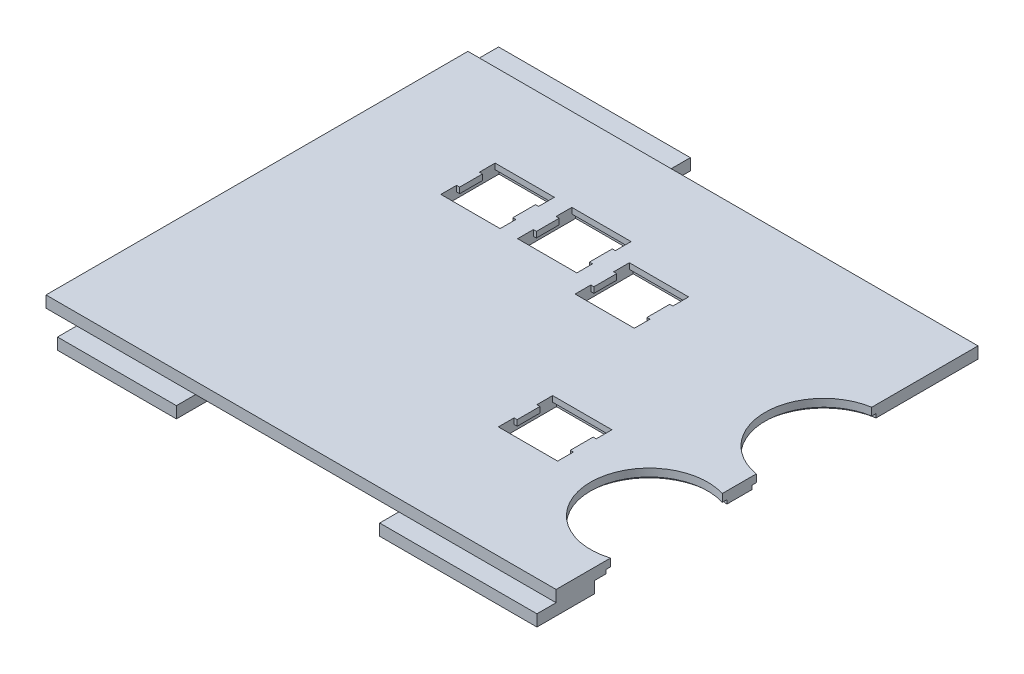
from build123d import *

# Parameters (mm, degrees)
SKETCH1_W           = 133
SKETCH1_H           = 110
BOSS_EXTRUDE1_DEPTH = 3
SKETCH2_W           = 50
SKETCH2_H           = 18
SKETCH2_W_2         = 41
SKETCH2_H_2         = 15
SKETCH2_W_3         = 31
BOSS_EXTRUDE2_DEPTH = 3
CUT_EXTRUDE1_REACH  = 8
SKETCH3_R           = 15.25
SKETCH4_R           = 16.375
CUT_EXTRUDE2_DEPTH  = 1
CUT_EXTRUDE3_DEPTH  = 7
SKETCH7_W           = 15.45
SKETCH7_H           = 16.15
CUT_EXTRUDE4_DEPTH  = 1.5


with BuildPart() as part:
    # Sketch1 → Boss-Extrude1 (new body)
    with BuildSketch(Plane(origin=(0, 0, 0), x_dir=(1, 0, 0), z_dir=(0, 1, 0))):
        with Locations((66.5, 55)):
            Rectangle(SKETCH1_W, SKETCH1_H)
    extrude(amount=BOSS_EXTRUDE1_DEPTH)

    # Sketch2 → Boss-Extrude2 (add)
    with BuildSketch(Plane.XZ):
        with Locations((25, -109)):
            Rectangle(SKETCH2_W, SKETCH2_H)
        with Locations((112.5, -2.5)):
            Rectangle(SKETCH2_W_2, SKETCH2_H_2)
        with Locations((23.5, -2.5)):
            Rectangle(SKETCH2_W_3, SKETCH2_H_2)
    extrude(amount=BOSS_EXTRUDE2_DEPTH)

    # Sketch3 → Cut-Extrude1 (cut, up to next)
    with BuildSketch(Plane(origin=(0, 3, 0), x_dir=(1, 0, 0), z_dir=(0, 1, 0)), mode=Mode.PRIVATE) as cut_extrude1_sk1:
        with Locations((128.5, 28.75)):
            Circle(SKETCH3_R)
    cut_extrude1_tool1 = extrude(cut_extrude1_sk1.sketch, amount=-CUT_EXTRUDE1_REACH, mode=Mode.PRIVATE) & part.part
    add(cut_extrude1_tool1.solids().sort_by_distance((128.5, 3, -28.75))[0], mode=Mode.SUBTRACT)
    # Sketch3 → Cut-Extrude1 (cut, up to next)
    with BuildSketch(Plane(origin=(0, 3, 0), x_dir=(1, 0, 0), z_dir=(0, 1, 0)), mode=Mode.PRIVATE) as cut_extrude1_sk2:
        with Locations((135.5, 67.25)):
            Circle(SKETCH3_R)
    cut_extrude1_tool2 = extrude(cut_extrude1_sk2.sketch, amount=-CUT_EXTRUDE1_REACH, mode=Mode.PRIVATE) & part.part
    add(cut_extrude1_tool2.solids().sort_by_distance((135.5, 3, -67.25))[0], mode=Mode.SUBTRACT)

    # Sketch4 → Cut-Extrude2 (cut)
    with BuildSketch(Plane.XZ):
        with Locations((128.5, -28.75)):
            Circle(SKETCH4_R)
        with Locations((135.5, -67.25)):
            Circle(SKETCH4_R)
    extrude(amount=-CUT_EXTRUDE2_DEPTH, mode=Mode.SUBTRACT)

    # Sketch6 → Cut-Extrude3 (cut, through all)
    with BuildSketch(Plane(origin=(0, 3, 0), x_dir=(1, 0, 0), z_dir=(0, 1, 0))):
        Polygon((29.575, 84.225), (29.575, 78.275), (28.775, 78.275), (28.775, 74.175), (44.225, 74.175), (44.225, 78.275), (43.425, 78.275), (43.425, 84.225), (44.225, 84.225), (44.225, 88.325), (28.775, 88.325), (28.775, 84.225), align=None)
        Polygon((49.575, 84.225), (49.575, 78.275), (48.775, 78.275), (48.775, 74.175), (64.225, 74.175), (64.225, 78.275), (63.425, 78.275), (63.425, 84.225), (64.225, 84.225), (64.225, 88.325), (48.775, 88.325), (48.775, 84.225), align=None)
        Polygon((69.575, 79.225), (69.575, 73.275), (68.775, 73.275), (68.775, 69.175), (84.225, 69.175), (84.225, 73.275), (83.425, 73.275), (83.425, 79.225), (84.225, 79.225), (84.225, 83.325), (68.775, 83.325), (68.775, 79.225), align=None)
        Polygon((89.575, 39.225), (89.575, 33.275), (88.775, 33.275), (88.775, 29.175), (104.225, 29.175), (104.225, 33.275), (103.425, 33.275), (103.425, 39.225), (104.225, 39.225), (104.225, 43.325), (88.775, 43.325), (88.775, 39.225), align=None)
    extrude(amount=-CUT_EXTRUDE3_DEPTH, mode=Mode.SUBTRACT)

    # Sketch7 → Cut-Extrude4 (cut)
    with BuildSketch(Plane.XZ):
        with Locations((76.5, -76.25)):
            Rectangle(SKETCH7_W, SKETCH7_H)
        with Locations((96.5, -36.25)):
            Rectangle(SKETCH7_W, SKETCH7_H)
        with Locations((56.5, -81.25)):
            Rectangle(SKETCH7_W, SKETCH7_H)
        with Locations((36.5, -81.25)):
            Rectangle(SKETCH7_W, SKETCH7_H)
    extrude(amount=-CUT_EXTRUDE4_DEPTH, mode=Mode.SUBTRACT)


solid = part.part
